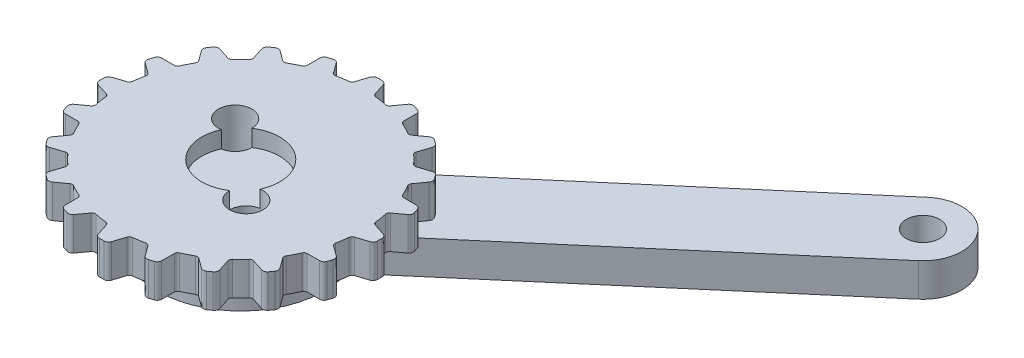
from build123d import *

# Parameters (mm, degrees)
SKETCH1_R                = 11
SKETCH1_R_2              = 3.5
BOSS_EXTRUDE1_DEPTH      = 1.5
BOSS_EXTRUDE2_DEPTH      = 1.5
FILLET1_R                = 0.3
CIRPATTERN1_COUNT        = 20
FILLET1_OF_CIRPATTERN1_R = 0.3
BOSS_EXTRUDE3_START      = 3
BOSS_EXTRUDE3_DEPTH      = 3
SKETCH3_R                = 1.500000003
CUT_EXTRUDE1_DEPTH       = 49.510023357
SKETCH1_4_R              = 7.5
BOSS_EXTRUDE4_DEPTH      = 5
CUT_EXTRUDE2_DEPTH       = 49.851533917
CUT_EXTRUDE2_DEPTH_BACK  = 49.851533917
SKETCH4_R                = 1.5


with BuildPart() as part:
    # Sketch1 → Boss-Extrude1 (new, symmetric)
    with BuildSketch(Plane(origin=(0, 0, 0), x_dir=(1, 0, 0), z_dir=(0, 1, 0))):
        Circle(SKETCH1_R)
        Circle(SKETCH1_R_2, mode=Mode.SUBTRACT)
    extrude(amount=BOSS_EXTRUDE1_DEPTH, both=True)

    # Sketch1_3 → Boss-Extrude2 (add, symmetric)
    with BuildSketch(Plane(origin=(0, 0, 0), x_dir=(1, 0, 0), z_dir=(0, 1, 0))):
        with BuildLine():
            Line((-0.589920274, 12.21384277), (-1, 10.95445115))
            ThreePointArc((-1, 10.95445115), (0, 11), (1, 10.95445115))
            Line((1, 10.95445115), (0.589920274, 12.21384277))
            ThreePointArc((0.589920274, 12.21384277), (0.444587735, 12.413676943), (0.209575724, 12.489995997))
            Line((0.209575724, 12.489995997), (-0.209575724, 12.489995997))
            ThreePointArc((-0.209575724, 12.489995997), (-0.444587735, 12.413676943), (-0.589920274, 12.21384277))
        make_face()
    boss_extrude2 = extrude(amount=BOSS_EXTRUDE2_DEPTH, both=True)

    # Fillet1
    fillet1_edges = [part.edges().sort_by_distance(p)[0] for p in [
        (1, 0, -10.95445115),
        (-1, 0, -10.95445115),
    ]]
    fillet(fillet1_edges, radius=FILLET1_R)

    # CirPattern1: Boss-Extrude2 ×20 about axis
    cirpattern1_axis = Axis((0, 1.5, 0), (0, 1, 0))
    for i in range(1, CIRPATTERN1_COUNT):
        add(boss_extrude2.rotate(cirpattern1_axis, i * 360 / CIRPATTERN1_COUNT))

    # Fillet1 of CirPattern1
    fillet1_of_cirpattern1_edges = [part.edges().sort_by_distance(p)[0] for p in [
        (-2.434055053, 0, -10.727319143),
        (-4.336168086, 0, -10.109285154),
        (-5.629847839, 0, -9.450122397),
        (-7.247881827, 0, -8.274551892),
        (-8.274551892, 0, -7.247881827),
        (-9.450122397, 0, -5.629847839),
        (-10.109285154, 0, -4.336168086),
        (-10.727319143, 0, -2.434055053),
        (-10.95445115, 0, -1),
        (-10.95445115, 0, 1),
        (-10.727319143, 0, 2.434055053),
        (-10.109285154, 0, 4.336168086),
        (-9.450122397, 0, 5.629847839),
        (-8.274551892, 0, 7.247881827),
        (-7.247881827, 0, 8.274551892),
        (-5.629847839, 0, 9.450122397),
        (-4.336168086, 0, 10.109285154),
        (-2.434055053, 0, 10.727319143),
        (-1, 0, 10.95445115),
        (1, 0, 10.95445115),
        (2.434055053, 0, 10.727319143),
        (4.336168086, 0, 10.109285154),
        (5.629847839, 0, 9.450122397),
        (7.247881827, 0, 8.274551892),
        (8.274551892, 0, 7.247881827),
        (9.450122397, 0, 5.629847839),
        (10.109285154, 0, 4.336168086),
        (10.727319143, 0, 2.434055053),
        (10.95445115, 0, 1),
        (10.95445115, 0, -1),
        (10.727319143, 0, -2.434055053),
        (10.109285154, 0, -4.336168086),
        (9.450122397, 0, -5.629847839),
        (8.274551892, 0, -7.247881827),
        (7.247881827, 0, -8.274551892),
        (5.629847839, 0, -9.450122397),
        (4.336168086, 0, -10.109285154),
        (2.434055053, 0, -10.727319143),
    ]]
    fillet(fillet1_of_cirpattern1_edges, radius=FILLET1_OF_CIRPATTERN1_R)

    # Sketch2 → Boss-Extrude3 (add)
    with BuildSketch(Plane.XZ.offset(1.5).offset(BOSS_EXTRUDE3_START)):
        with BuildLine():
            Line((35.336996528, -25.576464122), (2.273004069, 2.661475659))
            ThreePointArc((2.273004069, 2.661475659), (2.661475637, -2.273004016), (-2.273004035, -2.66147562))
            Line((-2.273004035, -2.66147562), (30.790988424, -30.899415401))
            ThreePointArc((30.790988424, -30.899415401), (35.725468116, -30.510943813), (35.336996528, -25.576464122))
        make_face()
    extrude(amount=-BOSS_EXTRUDE3_DEPTH)

    # Sketch3 → Cut-Extrude1 (cut, through all)
    with BuildSketch(Plane(origin=(0, -1.5, 0), x_dir=(1, 0, 0), z_dir=(0, 1, 0))):
        with Locations((33.063992476, 28.237939761)):
            Circle(SKETCH3_R)
    extrude(amount=-CUT_EXTRUDE1_DEPTH, mode=Mode.SUBTRACT)

    # Sketch1_4 → Boss-Extrude4 (add)
    with BuildSketch(Plane(origin=(0, 0, 0), x_dir=(1, 0, 0), z_dir=(0, 1, 0))):
        Circle(SKETCH1_4_R)
    extrude(amount=-BOSS_EXTRUDE4_DEPTH)

    # Sketch4 → Cut-Extrude2 (cut, two sides: drawn at the far end of the back side and taken through both)
    with BuildSketch(Plane.XZ.offset(5).offset(-CUT_EXTRUDE2_DEPTH_BACK)):
        with Locations((3.421897262, 2.922433768)):
            Circle(SKETCH4_R)
        with Locations((-3.421897262, -2.922433768)):
            Circle(SKETCH4_R)
    extrude(amount=CUT_EXTRUDE2_DEPTH + CUT_EXTRUDE2_DEPTH_BACK, mode=Mode.SUBTRACT)


solid = part.part
